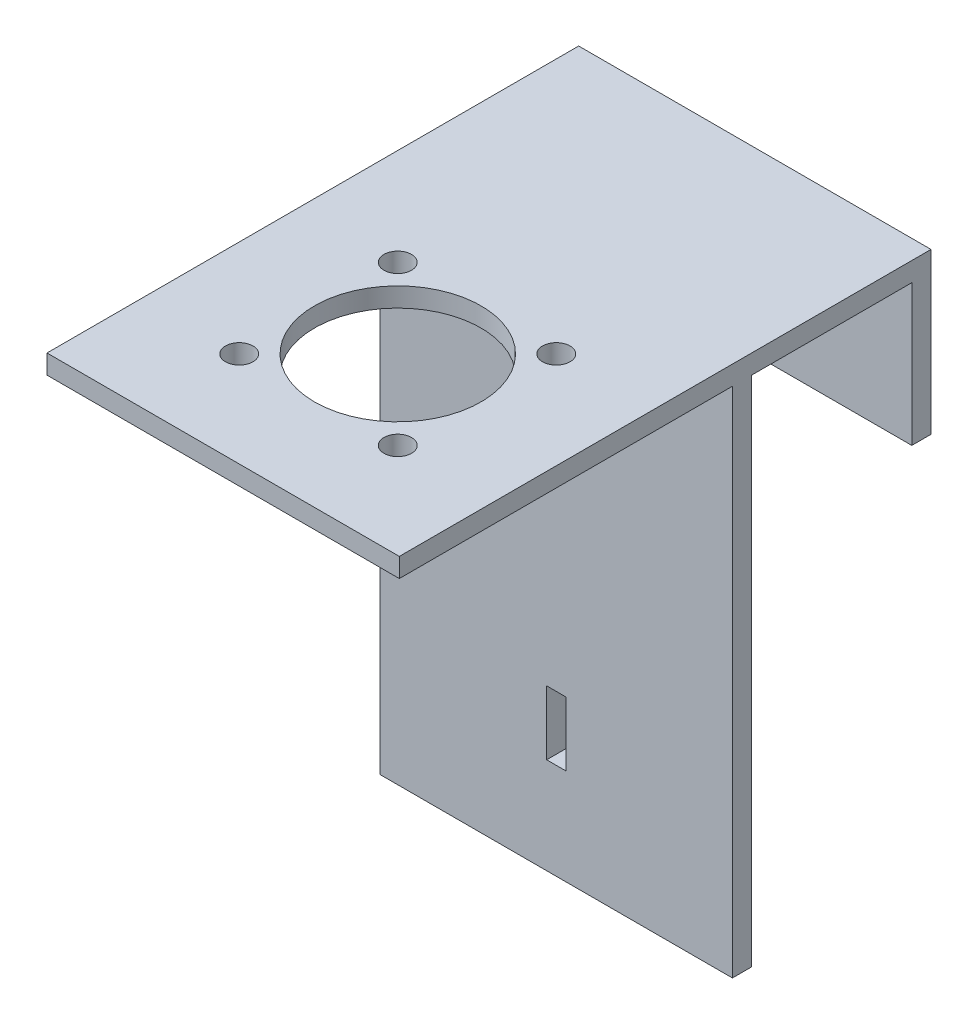
from build123d import *

# Parameters (mm, degrees)
SKETCH1_W           = 55
SKETCH1_H           = 80
SKETCH1_R           = 13
SKETCH1_R_2         = 2.15
BOSS_EXTRUDE2_DEPTH = 3
SKETCH2_W           = 55
SKETCH2_H           = 3
BOSS_EXTRUDE3_DEPTH = 80
SKETCH3_W           = 3
SKETCH3_H           = 10
CUT_EXTRUDE1_DEPTH  = 80
SKETCH4_W           = 55
SKETCH4_H           = 25
BOSS_EXTRUDE4_DEPTH = 3


with BuildPart() as part:
    # Sketch1 → Boss-Extrude2 (new body)
    with BuildSketch(Plane(origin=(0, 0, 0), x_dir=(1, 0, 0), z_dir=(0, 1, 0))):
        Rectangle(SKETCH1_W, SKETCH1_H)
        with Locations((0, -12.743931666)):
            Circle(SKETCH1_R, mode=Mode.SUBTRACT)
        with Locations((12.374368671, -0.369562995)):
            Circle(SKETCH1_R_2, mode=Mode.SUBTRACT)
        with Locations((12.374368671, -25.118300337)):
            Circle(SKETCH1_R_2, mode=Mode.SUBTRACT)
        with Locations((-12.374368671, -25.118300337)):
            Circle(SKETCH1_R_2, mode=Mode.SUBTRACT)
        with Locations((-12.374368671, -0.369562995)):
            Circle(SKETCH1_R_2, mode=Mode.SUBTRACT)
    extrude(amount=BOSS_EXTRUDE2_DEPTH)

    # Sketch2 → Boss-Extrude3 (add)
    with BuildSketch(Plane.XZ):
        with Locations((0, -13.5)):
            Rectangle(SKETCH2_W, SKETCH2_H)
    extrude(amount=BOSS_EXTRUDE3_DEPTH)

    # Sketch3 → Cut-Extrude1 (cut)
    with BuildSketch(Plane(origin=(0, 0, -15), x_dir=(-1, 0, 0), z_dir=(0, 0, -1))):
        with Locations((0, -60)):
            Rectangle(SKETCH3_W, SKETCH3_H)
    extrude(amount=-CUT_EXTRUDE1_DEPTH, mode=Mode.SUBTRACT)

    # Sketch4 → Boss-Extrude4 (add)
    with BuildSketch(Plane(origin=(0, 0, -40), x_dir=(-1, 0, 0), z_dir=(0, 0, -1))):
        with Locations((0, -9.5)):
            Rectangle(SKETCH4_W, SKETCH4_H)
    extrude(amount=BOSS_EXTRUDE4_DEPTH)


solid = part.part
